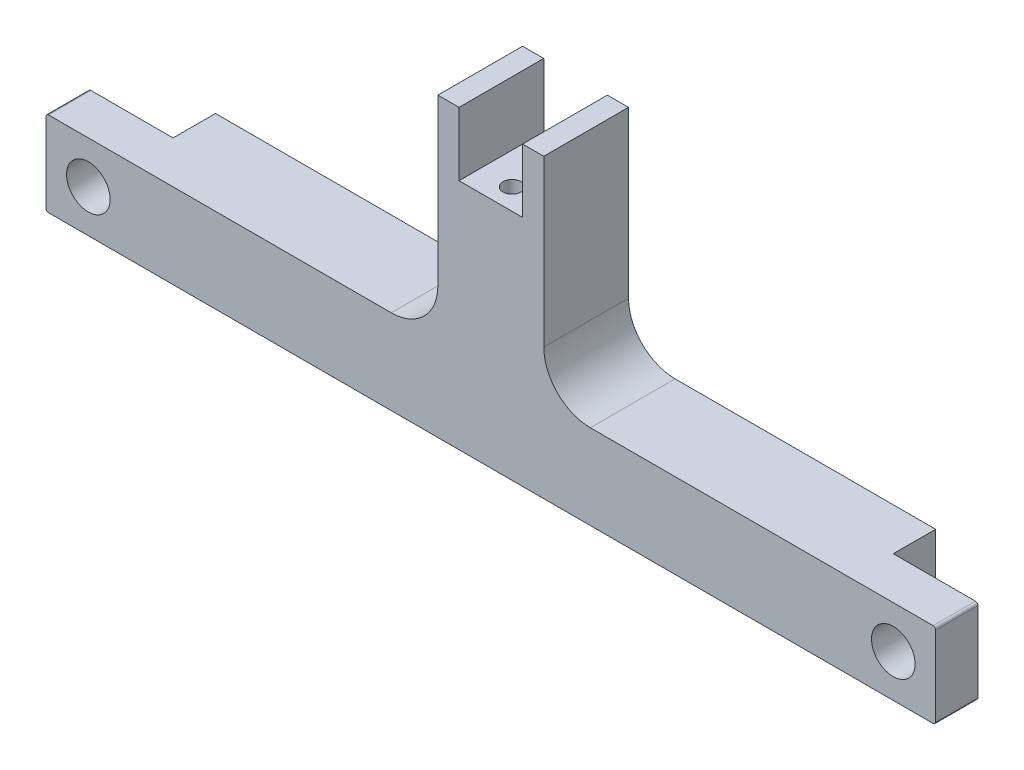
from build123d import *

# Parameters (mm, degrees)
SKETCH1_R                 = 3.2639
BOSS_EXTRUDE1_DEPTH       = 12.7
SKETCH2_W                 = 12.7
SKETCH2_H                 = 12.7
CUT_EXTRUDE1_DEPTH        = 6.35
SKETCH3_W                 = 9.525
SKETCH3_H                 = 12.7
CUT_EXTRUDE2_DEPTH        = 9.525
F_6_32_TAPPED_HOLE1_D     = 2.7051
F_6_32_TAPPED_HOLE1_DEPTH = 15.875
F_6_32_TAPPED_HOLE1_TIP   = 0.81269403


with BuildPart() as part:
    # Sketch1 → Boss-Extrude1 (new body)
    with BuildSketch(Plane.XY):
        with BuildLine():
            Line((-7.9375, 13.335), (-7.9375, 38.1))
            Line((-7.9375, 38.1), (7.9375, 38.1))
            Line((7.9375, 38.1), (7.9375, 13.335))
            ThreePointArc((7.9375, 13.335), (9.983359133, 8.395859133), (14.9225, 6.35))
            Line((14.9225, 6.35), (66.294, 6.35))
            ThreePointArc((66.294, 6.35), (66.563407684, 6.238407684), (66.675, 5.969))
            Line((66.675, 5.969), (66.675, -5.969))
            ThreePointArc((66.675, -5.969), (66.563407684, -6.238407684), (66.294, -6.35))
            Line((66.294, -6.35), (-66.294, -6.35))
            ThreePointArc((-66.294, -6.35), (-66.563407684, -6.238407684), (-66.675, -5.969))
            Line((-66.675, -5.969), (-66.675, 5.969))
            ThreePointArc((-66.675, 5.969), (-66.563407684, 6.238407684), (-66.294, 6.35))
            Line((-66.294, 6.35), (-14.9225, 6.35))
            ThreePointArc((-14.9225, 6.35), (-9.983359133, 8.395859133), (-7.9375, 13.335))
        make_face()
        with Locations((-60.325, 0)):
            Circle(SKETCH1_R, mode=Mode.SUBTRACT)
        with Locations((60.325, 0)):
            Circle(SKETCH1_R, mode=Mode.SUBTRACT)
    extrude(amount=BOSS_EXTRUDE1_DEPTH)

    # Sketch2 → Cut-Extrude1 (cut)
    with BuildSketch(Plane(origin=(0, 0, 0), x_dir=(-1, 0, 0), z_dir=(0, 0, -1))):
        with Locations((-60.325, 0)):
            Rectangle(SKETCH2_W, SKETCH2_H)
        with Locations((60.325, 0)):
            Rectangle(SKETCH2_W, SKETCH2_H)
    extrude(amount=-CUT_EXTRUDE1_DEPTH, mode=Mode.SUBTRACT)

    # Sketch3 → Cut-Extrude2 (cut)
    with BuildSketch(Plane(origin=(0, 38.1, 0), x_dir=(1, 0, 0), z_dir=(0, 1, 0))):
        with Locations((0, -6.35)):
            Rectangle(SKETCH3_W, SKETCH3_H)
    extrude(amount=-CUT_EXTRUDE2_DEPTH, mode=Mode.SUBTRACT)

    # #6-32 Tapped Hole1
    with Locations(Plane(origin=(0, 28.575, 0), x_dir=(1, 0, 0), z_dir=(0, 1, 0))):
        with Locations((0, -3.175), (0, -9.525)):
            Hole(F_6_32_TAPPED_HOLE1_D / 2, depth=F_6_32_TAPPED_HOLE1_DEPTH)
            with Locations((0, 0, -(F_6_32_TAPPED_HOLE1_DEPTH + F_6_32_TAPPED_HOLE1_TIP / 2))):  # 118° drill point
                Cone(0, F_6_32_TAPPED_HOLE1_D / 2, F_6_32_TAPPED_HOLE1_TIP, mode=Mode.SUBTRACT)


solid = part.part
